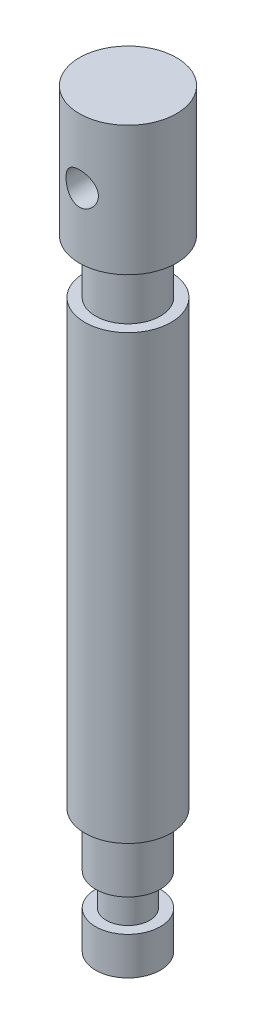
from build123d import *

# Parameters (mm, degrees)
SKETCH1_R               = 8
BOSS_EXTRUDE1_DEPTH     = 82
SKETCH2_R               = 6
BOSS_EXTRUDE2_DEPTH     = 10
SKETCH4_R               = 9
BOSS_EXTRUDE3_DEPTH     = 24
SKETCH5_R               = 6
BOSS_EXTRUDE4_DEPTH     = 10
SKETCH6_R               = 4
BOSS_EXTRUDE5_DEPTH     = 6
SKETCH7_R               = 6
BOSS_EXTRUDE6_DEPTH     = 7
SKETCH8_R               = 3
CUT_EXTRUDE2_DEPTH      = 10
CUT_EXTRUDE2_DEPTH_BACK = 10


with BuildPart() as part:
    # Sketch1 → Boss-Extrude1 (new body)
    with BuildSketch(Plane(origin=(0, 0, 0), x_dir=(1, 0, 0), z_dir=(0, 1, 0))):
        Circle(SKETCH1_R)
    extrude(amount=BOSS_EXTRUDE1_DEPTH)

    # Sketch2 → Boss-Extrude2 (add)
    with BuildSketch(Plane(origin=(0, 82, 0), x_dir=(1, 0, 0), z_dir=(0, 1, 0))):
        Circle(SKETCH2_R)
    extrude(amount=BOSS_EXTRUDE2_DEPTH)

    # Sketch4 → Boss-Extrude3 (add)
    with BuildSketch(Plane(origin=(0, 92, 0), x_dir=(1, 0, 0), z_dir=(0, 1, 0))):
        Circle(SKETCH4_R)
    extrude(amount=BOSS_EXTRUDE3_DEPTH)

    # Sketch5 → Boss-Extrude4 (add)
    with BuildSketch(Plane.XZ):
        Circle(SKETCH5_R)
    extrude(amount=BOSS_EXTRUDE4_DEPTH)

    # Sketch6 → Boss-Extrude5 (add)
    with BuildSketch(Plane.XZ.offset(10)):
        Circle(SKETCH6_R)
    extrude(amount=BOSS_EXTRUDE5_DEPTH)

    # Sketch7 → Boss-Extrude6 (add)
    with BuildSketch(Plane.XZ.offset(16)):
        Circle(SKETCH7_R)
    extrude(amount=BOSS_EXTRUDE6_DEPTH)

    # Sketch8 → Cut-Extrude2 (cut, two sides)
    with BuildSketch(Plane.XY) as cut_extrude2_sk:
        with Locations((0, 104)):
            Circle(SKETCH8_R)
    extrude(amount=CUT_EXTRUDE2_DEPTH, mode=Mode.SUBTRACT)
    extrude(cut_extrude2_sk.sketch, amount=-CUT_EXTRUDE2_DEPTH_BACK, mode=Mode.SUBTRACT)


solid = part.part
